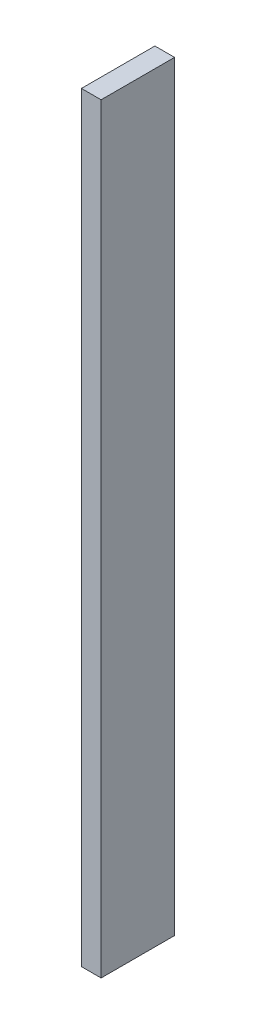
from build123d import *

# Parameters (mm, degrees)
SKETCH1_W           = 11.2
SKETCH1_H           = 115.957009142
BOSS_EXTRUDE1_DEPTH = 3


with BuildPart() as part:
    # Sketch1 → Boss-Extrude1 (new body)
    with BuildSketch(Plane(origin=(0, 0, 0), x_dir=(0, 0, -1), z_dir=(1, 0, 0))):
        with Locations((5.6, 57.978504571)):
            Rectangle(SKETCH1_W, SKETCH1_H)
    extrude(amount=-BOSS_EXTRUDE1_DEPTH)


solid = part.part
